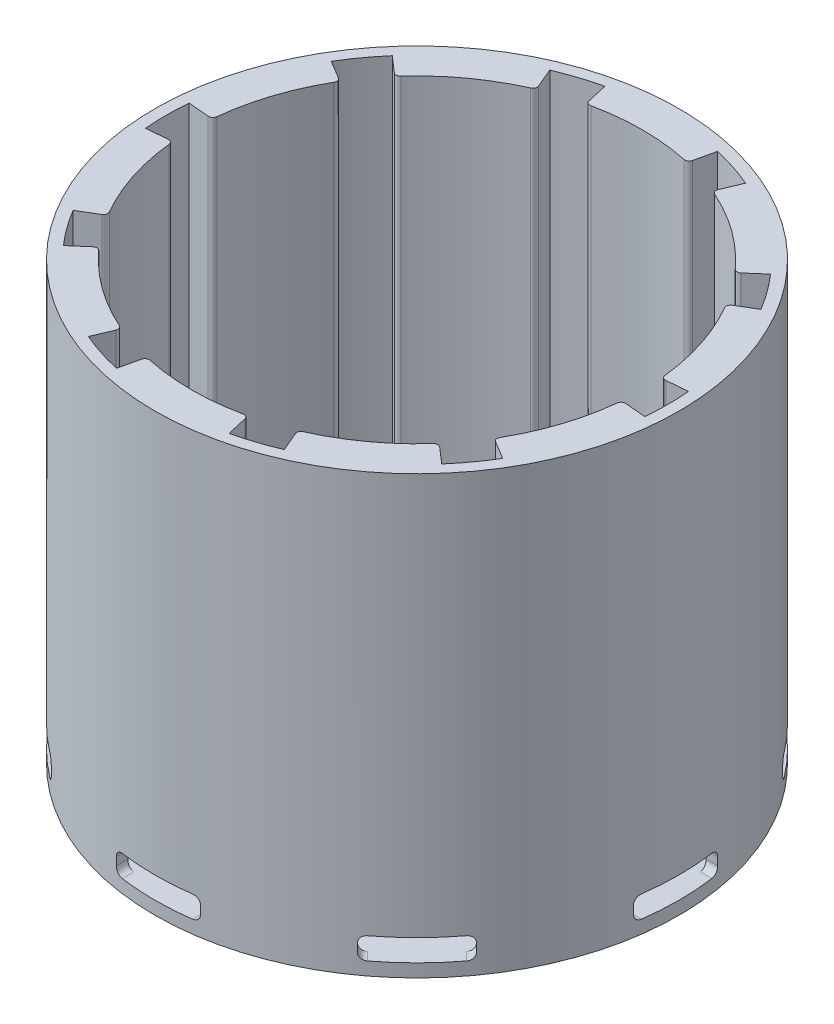
from build123d import *

# Parameters (mm, degrees)
SKETCH1_W           = 60
SKETCH1_H           = 60
BOSS_EXTRUDE2_DEPTH = 50
CUT_EXTRUDE1_DEPTH  = 49.5
SKETCH3_OUTSIDE_W   = 81.698
SKETCH3_OUTSIDE_H   = 81.698
SKETCH3_OUTSIDE_R   = 30
CUT_EXTRUDE2_DEPTH  = 50
CIRPATTERN1_COUNT   = 8
SKETCH4_R           = 25.8
CUT_EXTRUDE3_DEPTH  = 48.5
CUT_EXTRUDE5_DEPTH  = 48.5
SKETCH6_R           = 28.7
CUT_EXTRUDE6_DEPTH  = 4
SKETCH12_R          = 4
CUT_EXTRUDE8_DEPTH  = 70


with BuildPart() as part:
    # Sketch1 → Boss-Extrude2 (new body)
    with BuildSketch(Plane(origin=(0, 0, 0), x_dir=(1, 0, 0), z_dir=(0, 1, 0))):
        Rectangle(SKETCH1_W, SKETCH1_H)
    extrude(amount=BOSS_EXTRUDE2_DEPTH)

    # Sketch2 → Cut-Extrude1 (cut)
    with BuildSketch(Plane.XY.offset(30)):
        with BuildLine():
            Line((-4.025, 4), (4.025, 4))
            ThreePointArc((4.025, 4), (4.590685425, 3.765685425), (4.825, 3.2))
            Line((4.825, 3.2), (4.825, 2.3))
            ThreePointArc((4.825, 2.3), (4.590685425, 1.734314575), (4.025, 1.5))
            Line((4.025, 1.5), (-4.025, 1.5))
            ThreePointArc((-4.025, 1.5), (-4.590685425, 1.734314575), (-4.825, 2.3))
            Line((-4.825, 2.3), (-4.825, 3.2))
            ThreePointArc((-4.825, 3.2), (-4.590685425, 3.765685425), (-4.025, 4))
        make_face()
    cut_extrude1 = extrude(amount=-CUT_EXTRUDE1_DEPTH, mode=Mode.SUBTRACT)

    # Sketch3 outside → Cut-Extrude2 (cut)
    with BuildSketch(Plane(origin=(0, 50, 0), x_dir=(1, 0, 0), z_dir=(0, 1, 0))):
        Rectangle(SKETCH3_OUTSIDE_W, SKETCH3_OUTSIDE_H)
        Circle(SKETCH3_OUTSIDE_R, mode=Mode.SUBTRACT)
    extrude(amount=-CUT_EXTRUDE2_DEPTH, mode=Mode.SUBTRACT)

    # CirPattern1: Cut-Extrude1 ×8 about axis
    cirpattern1_axis = Axis((0, 0, 0), (0, 1, 0))
    for i in range(1, CIRPATTERN1_COUNT):
        add(cut_extrude1.rotate(cirpattern1_axis, i * 360 / CIRPATTERN1_COUNT), mode=Mode.SUBTRACT)

    # Sketch4 → Cut-Extrude3 (cut)
    with BuildSketch(Plane(origin=(0, 50, 0), x_dir=(1, 0, 0), z_dir=(0, 1, 0))):
        Circle(SKETCH4_R)
    extrude(amount=-CUT_EXTRUDE3_DEPTH, mode=Mode.SUBTRACT)

    # Sketch5 → Cut-Extrude5 (cut)
    with BuildSketch(Plane(origin=(0, 50, 0), x_dir=(1, 0, 0), z_dir=(0, 1, 0))):
        with BuildLine():
            ThreePointArc((-21.660164952, 18.828894132), (-23.218787739, 16.869436741), (-24.60070153, 14.78159275))
            Line((-24.60070153, 14.78159275), (-22.539425651, 13.543053249))
            ThreePointArc((-22.539425651, 13.543053249), (-22.312968617, 13.240036961), (-22.363542698, 12.865145082))
            ThreePointArc((-22.363542698, 12.865145082), (-20.872638455, 15.164859509), (-19.146194811, 17.293444545))
            ThreePointArc((-19.146194811, 17.293444545), (-19.487109926, 17.129497774), (-19.845274613, 17.251234029))
            Line((-19.845274613, 17.251234029), (-21.660164952, 18.828894132))
        make_face()
        with BuildLine():
            ThreePointArc((-6.45609526, 27.964420859), (-8.868787739, 27.295322018), (-11.213983388, 26.418489294))
            Line((-11.213983388, 26.418489294), (-10.274371424, 24.204902227))
            ThreePointArc((-10.274371424, 24.204902227), (-10.269272341, 23.826648796), (-10.53054355, 23.553081593))
            ThreePointArc((-10.53054355, 23.553081593), (-7.972638455, 24.53725812), (-5.324765315, 25.244541476))
            ThreePointArc((-5.324765315, 25.244541476), (-5.69693693, 25.312290629), (-5.915143474, 25.621301249))
            Line((-5.915143474, 25.621301249), (-6.45609526, 27.964420859))
        make_face()
        with BuildLine():
            ThreePointArc((11.213983388, 26.418489294), (8.868787739, 27.295322018), (6.45609526, 27.964420859))
            Line((6.45609526, 27.964420859), (5.915143474, 25.621301249))
            ThreePointArc((5.915143474, 25.621301249), (5.69693693, 25.312290629), (5.324765315, 25.244541476))
            ThreePointArc((5.324765315, 25.244541476), (7.972638455, 24.53725812), (10.53054355, 23.553081593))
            ThreePointArc((10.53054355, 23.553081593), (10.269272341, 23.826648796), (10.274371424, 24.204902227))
            Line((10.274371424, 24.204902227), (11.213983388, 26.418489294))
        make_face()
        with BuildLine():
            Line((22.539425651, 13.543053249), (24.60070153, 14.78159275))
            ThreePointArc((24.60070153, 14.78159275), (23.218787739, 16.869436741), (21.660164952, 18.828894132))
            Line((21.660164952, 18.828894132), (19.845274613, 17.251234029))
            ThreePointArc((19.845274613, 17.251234029), (19.487109926, 17.129497774), (19.146194811, 17.293444545))
            ThreePointArc((19.146194811, 17.293444545), (20.872638455, 15.164859509), (22.363542698, 12.865145082))
            ThreePointArc((22.363542698, 12.865145082), (22.312968617, 13.240036961), (22.539425651, 13.543053249))
        make_face()
        with BuildLine():
            Line((26.195185366, -2.291781759), (28.590787835, -2.501369817))
            ThreePointArc((28.590787835, -2.501369817), (28.672683959, -1.251876417), (28.7, 0))
            ThreePointArc((28.7, 0), (28.672683959, 1.251876417), (28.590787835, 2.501369817))
            Line((28.590787835, 2.501369817), (26.195185366, 2.291781759))
            ThreePointArc((26.195185366, 2.291781759), (25.833869272, 2.40381898), (25.654428645, 2.736839581))
            ThreePointArc((25.654428645, 2.736839581), (25.763581458, 1.370354143), (25.8, 0))
            ThreePointArc((25.8, 0), (25.763581458, -1.370354143), (25.654428645, -2.736839581))
            ThreePointArc((25.654428645, -2.736839581), (25.833869272, -2.40381898), (26.195185366, -2.291781759))
        make_face()
        with BuildLine():
            Line((19.845274613, -17.251234029), (21.660164952, -18.828894132))
            ThreePointArc((21.660164952, -18.828894132), (23.218787739, -16.869436741), (24.60070153, -14.78159275))
            Line((24.60070153, -14.78159275), (22.539425651, -13.543053249))
            ThreePointArc((22.539425651, -13.543053249), (22.312968617, -13.240036961), (22.363542698, -12.865145082))
            ThreePointArc((22.363542698, -12.865145082), (20.872638455, -15.164859509), (19.146194811, -17.293444545))
            ThreePointArc((19.146194811, -17.293444545), (19.487109926, -17.129497774), (19.845274613, -17.251234029))
        make_face()
        with BuildLine():
            Line((5.915143474, -25.621301249), (6.45609526, -27.964420859))
            ThreePointArc((6.45609526, -27.964420859), (8.868787739, -27.295322018), (11.213983388, -26.418489294))
            Line((11.213983388, -26.418489294), (10.274371424, -24.204902227))
            ThreePointArc((10.274371424, -24.204902227), (10.269272341, -23.826648796), (10.53054355, -23.553081593))
            ThreePointArc((10.53054355, -23.553081593), (7.972638455, -24.53725812), (5.324765315, -25.244541476))
            ThreePointArc((5.324765315, -25.244541476), (5.69693693, -25.312290629), (5.915143474, -25.621301249))
        make_face()
        with BuildLine():
            Line((-6.45609526, -27.964420859), (-5.915143474, -25.621301249))
            ThreePointArc((-5.915143474, -25.621301249), (-5.69693693, -25.312290629), (-5.324765315, -25.244541476))
            ThreePointArc((-5.324765315, -25.244541476), (-7.972638455, -24.53725812), (-10.53054355, -23.553081593))
            ThreePointArc((-10.53054355, -23.553081593), (-10.269272341, -23.826648796), (-10.274371424, -24.204902227))
            Line((-10.274371424, -24.204902227), (-11.213983388, -26.418489294))
            ThreePointArc((-11.213983388, -26.418489294), (-8.868787739, -27.295322018), (-6.45609526, -27.964420859))
        make_face()
        with BuildLine():
            ThreePointArc((-24.60070153, -14.78159275), (-23.218787739, -16.869436741), (-21.660164952, -18.828894132))
            Line((-21.660164952, -18.828894132), (-19.845274613, -17.251234029))
            ThreePointArc((-19.845274613, -17.251234029), (-19.487109926, -17.129497774), (-19.146194811, -17.293444545))
            ThreePointArc((-19.146194811, -17.293444545), (-20.872638455, -15.164859509), (-22.363542698, -12.865145082))
            ThreePointArc((-22.363542698, -12.865145082), (-22.312968617, -13.240036961), (-22.539425651, -13.543053249))
            Line((-22.539425651, -13.543053249), (-24.60070153, -14.78159275))
        make_face()
        with BuildLine():
            ThreePointArc((-28.590787835, 2.501369817), (-28.7, 0), (-28.590787835, -2.501369817))
            Line((-28.590787835, -2.501369817), (-26.195185366, -2.291781759))
            ThreePointArc((-26.195185366, -2.291781759), (-25.833869272, -2.40381898), (-25.654428645, -2.736839581))
            ThreePointArc((-25.654428645, -2.736839581), (-25.8, 0), (-25.654428645, 2.736839581))
            ThreePointArc((-25.654428645, 2.736839581), (-25.833869272, 2.40381898), (-26.195185366, 2.291781759))
            Line((-26.195185366, 2.291781759), (-28.590787835, 2.501369817))
        make_face()
    extrude(amount=-CUT_EXTRUDE5_DEPTH, mode=Mode.SUBTRACT)

    # Sketch6 → Cut-Extrude6 (cut)
    with BuildSketch(Plane(origin=(0, 1.5, 0), x_dir=(1, 0, 0), z_dir=(0, 1, 0))):
        Circle(SKETCH6_R)
    extrude(amount=CUT_EXTRUDE6_DEPTH, mode=Mode.SUBTRACT)

    # Sketch12 → Cut-Extrude8 (cut)
    with BuildSketch(Plane.XZ):
        Circle(SKETCH12_R)
    extrude(amount=-CUT_EXTRUDE8_DEPTH, mode=Mode.SUBTRACT)


solid = part.part
